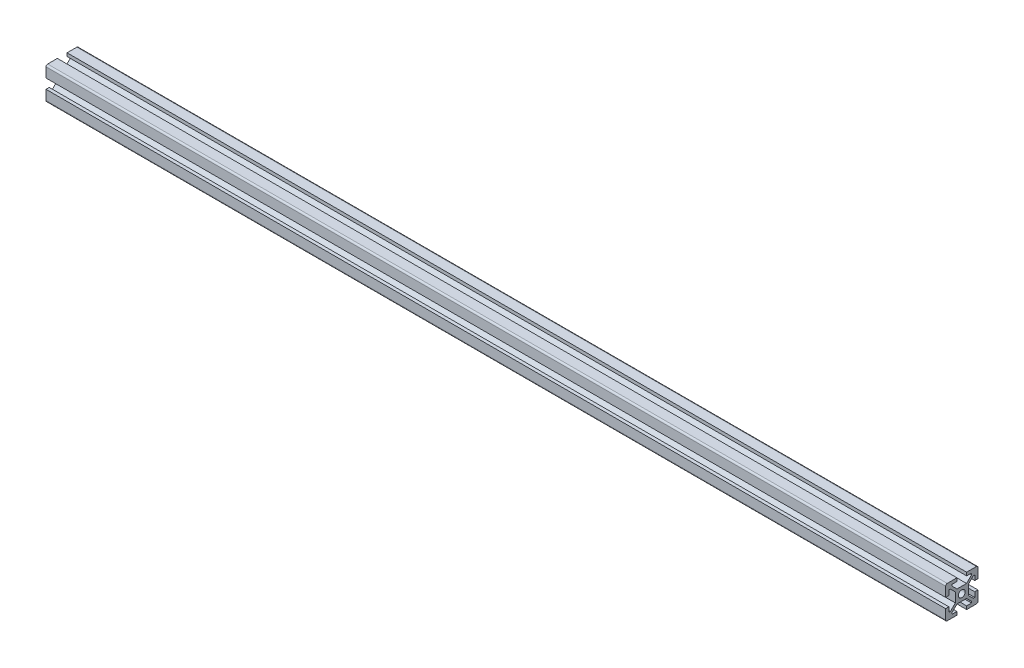
from build123d import *

# Parameters (mm, degrees)
SKETCH1_R           = 2.1
BOSS_EXTRUDE1_DEPTH = 555


with BuildPart() as part:
    # Sketch1 → Boss-Extrude1 (new body)
    with BuildSketch(Plane(origin=(0, 0, 0), x_dir=(0, 0, -1), z_dir=(1, 0, 0))):
        with BuildLine():
            Line((-10, 9), (-10, 3))
            Line((-10, 3), (-8, 3))
            Line((-8, 3), (-8, 6))
            Line((-8, 6), (-7.060660172, 6))
            Line((-7.060660172, 6), (-4, 2.939339828))
            Line((-4, 2.939339828), (-4, -2.939339828))
            Line((-4, -2.939339828), (-7.060660172, -6))
            Line((-7.060660172, -6), (-8, -6))
            Line((-8, -6), (-8, -3))
            Line((-8, -3), (-10, -3))
            Line((-10, -3), (-10, -9))
            ThreePointArc((-10, -9), (-9.707106781, -9.707106781), (-9, -10))
            Line((-9, -10), (-3, -10))
            Line((-3, -10), (-3, -8))
            Line((-3, -8), (-6, -8))
            Line((-6, -8), (-6, -7.060660172))
            Line((-6, -7.060660172), (-2.939339828, -4))
            Line((-2.939339828, -4), (2.939339828, -4))
            Line((2.939339828, -4), (6, -7.060660172))
            Line((6, -7.060660172), (6, -8))
            Line((6, -8), (3, -8))
            Line((3, -8), (3, -10))
            Line((3, -10), (9, -10))
            ThreePointArc((9, -10), (9.707106781, -9.707106781), (10, -9))
            Line((10, -9), (10, -3))
            Line((10, -3), (8, -3))
            Line((8, -3), (8, -6))
            Line((8, -6), (7.060660172, -6))
            Line((7.060660172, -6), (4, -2.939339828))
            Line((4, -2.939339828), (4, 2.939339828))
            Line((4, 2.939339828), (7.060660172, 6))
            Line((7.060660172, 6), (8, 6))
            Line((8, 6), (8, 3))
            Line((8, 3), (10, 3))
            Line((10, 3), (10, 9))
            ThreePointArc((10, 9), (9.707106781, 9.707106781), (9, 10))
            Line((9, 10), (3, 10))
            Line((3, 10), (3, 8))
            Line((3, 8), (6, 8))
            Line((6, 8), (6, 7.060660172))
            Line((6, 7.060660172), (2.939339828, 4))
            Line((2.939339828, 4), (-2.939339828, 4))
            Line((-2.939339828, 4), (-6, 7.060660172))
            Line((-6, 7.060660172), (-6, 8))
            Line((-6, 8), (-3, 8))
            Line((-3, 8), (-3, 10))
            Line((-3, 10), (-9, 10))
            ThreePointArc((-9, 10), (-9.707106781, 9.707106781), (-10, 9))
        make_face()
        Circle(SKETCH1_R, mode=Mode.SUBTRACT)
    extrude(amount=BOSS_EXTRUDE1_DEPTH)


solid = part.part
